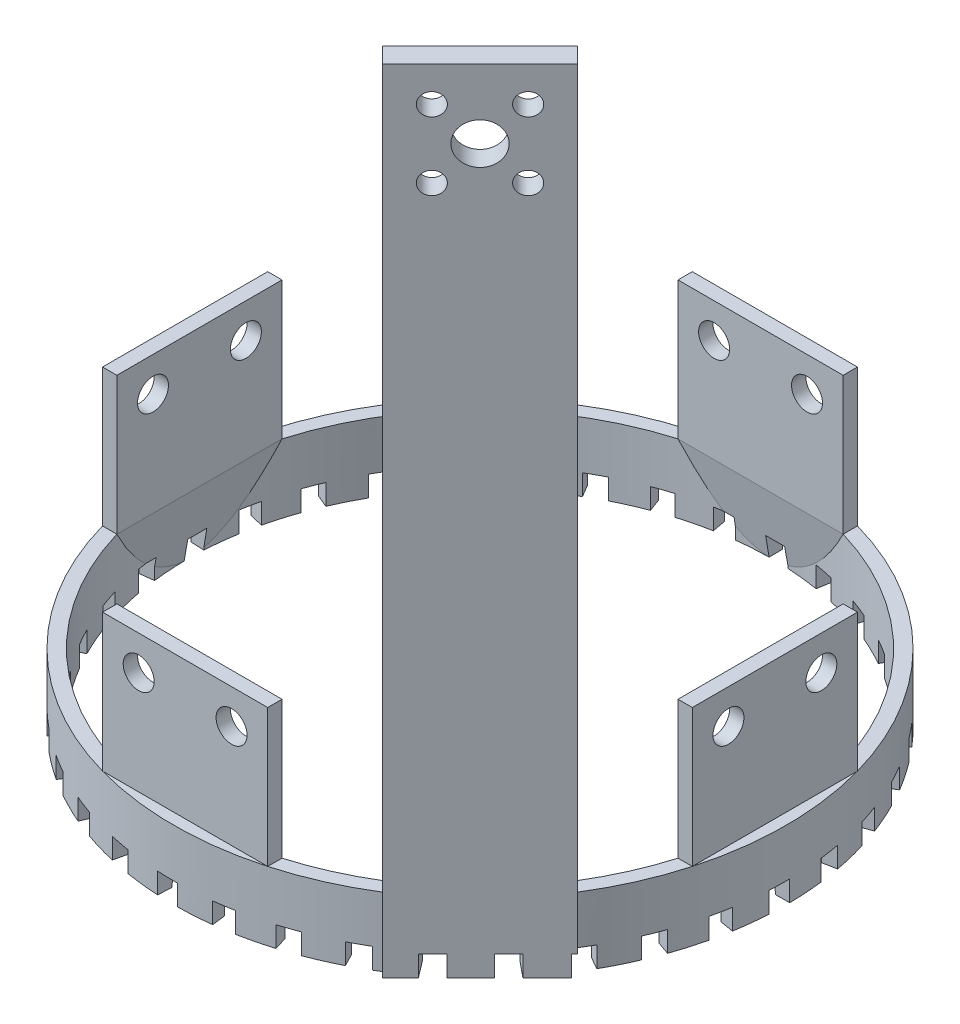
from build123d import *

# Parameters (mm, degrees)
SKETCH_1_R               = 44.5
SKETCH_1_R_2             = 42.5
EXTRUDE_1_DEPTH          = 10
SKETCH_6_W               = 24
SKETCH_6_H               = 2.080787458
SKETCH_6_W_2             = 2.080787458
SKETCH_6_H_2             = 24
EXTRUDE_3_DEPTH          = 20
SKETCH_7_R               = 2.25
CUT_EXTRUDE_1_DEPTH      = 90
SKETCH_8_R               = 2.25
CUT_EXTRUDE_2_DEPTH      = 90
EXTRUDE_4_DEPTH          = 24
EXTRUDE_5_DEPTH          = 24
EXTRUDE_6_DEPTH          = 105
EXTRUDE_6_DEPTH_BACK     = 10
EXTRUDE_11_DEPTH         = 20
SKETCH_14_R              = 1.6
SKETCH_14_R_2            = 3
CUT_EXTRUDE_4_DEPTH      = 20.570653934
CUT_EXTRUDE_4_DEPTH_BACK = 107.294353117
CUT_EXTRUDE_6_DEPTH      = 3


with BuildPart() as part:
    # 草图1 → 凸台-拉伸1 (new body)
    with BuildSketch(Plane(origin=(0, 0, 0), x_dir=(1, 0, 0), z_dir=(0, 1, 0))):
        Circle(SKETCH_1_R)
        Circle(SKETCH_1_R_2, mode=Mode.SUBTRACT)
    extrude(amount=EXTRUDE_1_DEPTH)

    # 草图6 → 凸台-拉伸3 (add)
    with BuildSketch(Plane(origin=(0, 10, 0), x_dir=(1, 0, 0), z_dir=(0, 1, 0))):
        with Locations((0, 41.811093993)):
            Rectangle(SKETCH_6_W, SKETCH_6_H)
        with Locations((41.811093993, 0)):
            Rectangle(SKETCH_6_W_2, SKETCH_6_H_2)
        with Locations((0, -41.811093993)):
            Rectangle(SKETCH_6_W, SKETCH_6_H)
        with Locations((-41.811093993, 0)):
            Rectangle(SKETCH_6_W_2, SKETCH_6_H_2)
    extrude(amount=EXTRUDE_3_DEPTH)

    # 草图7 → 切除-拉伸1 (cut, through all)
    with BuildSketch(Plane.ZY.offset(44.5)):
        with Locations((-6.75, 25)):
            Circle(SKETCH_7_R)
        with Locations((6.75, 25)):
            Circle(SKETCH_7_R)
    extrude(amount=-CUT_EXTRUDE_1_DEPTH, mode=Mode.SUBTRACT)

    # 草图8 → 切除-拉伸2 (cut, through all)
    with BuildSketch(Plane(origin=(0, 0, -44.5), x_dir=(-1, 0, 0), z_dir=(0, 0, -1))):
        with Locations((-6.75, 25)):
            Circle(SKETCH_8_R)
        with Locations((6.75, 25)):
            Circle(SKETCH_8_R)
    extrude(amount=-CUT_EXTRUDE_2_DEPTH, mode=Mode.SUBTRACT)

    # 草图9 → 凸台-拉伸4 (add)
    with BuildSketch(Plane(origin=(12, 0, 0), x_dir=(0, 0, -1), z_dir=(1, 0, 0))):
        Polygon((-42.851487722, 0), (-42.851487722, 10), (-40.770700264, 10), (-42.5, 0), align=None)
        Polygon((42.851487722, 10), (40.770700264, 10), (42.5, 0), (42.851487722, 0), align=None)
    extrude(amount=-EXTRUDE_4_DEPTH)

    # 草图10 → 凸台-拉伸5 (add)
    with BuildSketch(Plane.XY.offset(12)):
        Polygon((-42.851487722, 0), (-42.851487722, 10), (-40.770700264, 10), (-42.5, 0), align=None)
        Polygon((42.851487722, 10), (40.770700264, 10), (42.5, 0), (42.851487722, 0), align=None)
    extrude(amount=-EXTRUDE_5_DEPTH)

    # 草图12 → 凸台-拉伸6 (add, two sides)
    with BuildSketch(Plane(origin=(0, 10, 0), x_dir=(1, 0, 0), z_dir=(0, 1, 0))) as extrude_6_sk:
        Polygon((36.279371426, -22.137235802), (38.537319575, -24.395183951), (24.395183951, -38.537319575), (22.106388525, -36.248524149), align=None)
    extrude(amount=EXTRUDE_6_DEPTH)
    extrude(extrude_6_sk.sketch, amount=-EXTRUDE_6_DEPTH_BACK)

    # 草图13 → 凸台-拉伸11 (add)
    with BuildSketch(Plane(origin=(-7.071067812, 0, 7.071067812), x_dir=(0.707106781, 0, 0.707106781), z_dir=(-0.707106781, 0, 0.707106781))):
        Polygon((43.361849592, 10), (41.263154468, 10), (42.5, 0), (43.361849592, 0), align=None)
    extrude(amount=-EXTRUDE_11_DEPTH)

    # 草图14 → 切除-拉伸4 (cut, two sides)
    with BuildSketch(Plane(origin=(30.661457891, 0, 30.661457891), x_dir=(0.707106781, 0, -0.707106781), z_dir=(0.707106781, 0, 0.707106781))) as cut_extrude_4_sk:
        with Locations((4.949747468, 109.949747468)):
            Circle(SKETCH_14_R)
        with Locations((-4.949747468, 100.050252532)):
            Circle(SKETCH_14_R)
        with Locations((-4.949747468, 109.949747468)):
            Circle(SKETCH_14_R)
        with Locations((4.949747468, 100.050252532)):
            Circle(SKETCH_14_R)
        with Locations((0, 105)):
            Circle(SKETCH_14_R_2)
    extrude(amount=CUT_EXTRUDE_4_DEPTH, mode=Mode.SUBTRACT)
    extrude(cut_extrude_4_sk.sketch, amount=-CUT_EXTRUDE_4_DEPTH_BACK, mode=Mode.SUBTRACT)

    # 草图15 → 切除-拉伸6 (cut)
    with BuildSketch(Plane.XZ):
        with BuildLine():
            Line((-13.50434863, 38.469241844), (-15.107174155, 43.035140165))
            ThreePointArc((-15.107174155, 43.035140165), (-16.509241917, 42.516995794), (-17.893578126, 41.953186552))
            Line((-17.893578126, 41.953186552), (-16.014979854, 37.493605058))
            ThreePointArc((-16.014979854, 37.493605058), (-14.767723431, 38.002162368), (-13.50434863, 38.469241844))
        make_face()
        with BuildLine():
            Line((-9.260980133, 39.704965017), (-10.336640075, 44.423010613))
            ThreePointArc((-10.336640075, 44.423010613), (-8.875430597, 44.737866866), (-7.404688568, 45.004672949))
            Line((-7.404688568, 45.004672949), (-6.619073488, 40.229813151))
            ThreePointArc((-6.619073488, 40.229813151), (-7.944362286, 39.989212394), (-9.260980133, 39.704965017))
        make_face()
        with BuildLine():
            Line((-2.225590215, 40.709909705), (-2.465628447, 45.543063976))
            ThreePointArc((-2.465628447, 45.543063976), (-0.971943809, 45.599400492), (0.522784733, 45.606761518))
            Line((0.522784733, 45.606761518), (0.467318853, 40.768021942))
            ThreePointArc((0.467318853, 40.768021942), (-0.879615714, 40.761210436), (-2.225590215, 40.709909705))
        make_face()
        with BuildLine():
            Line((4.877423134, 40.477904387), (5.480300054, 45.279314387))
            ThreePointArc((5.480300054, 45.279314387), (6.961074999, 45.075419408), (8.434373485, 44.823111716))
            Line((8.434373485, 44.823111716), (7.539511947, 40.067515017))
            ThreePointArc((7.539511947, 40.067515017), (6.211857537, 40.294699725), (4.877423134, 40.477904387))
        make_face()
        with BuildLine():
            Line((11.83223845, 39.015998427), (13.259712412, 43.639775741))
            ThreePointArc((13.259712412, 43.639775741), (14.682585067, 43.181844516), (16.089688067, 42.677534347))
            Line((16.089688067, 42.677534347), (14.382620785, 38.149576922))
            ThreePointArc((14.382620785, 38.149576922), (13.11458664, 38.603854953), (11.83223845, 39.015998427))
        make_face()
        with BuildLine():
            Line((18.427537187, 36.368611098), (20.636235117, 40.674264593))
            ThreePointArc((20.636235117, 40.674264593), (21.957972216, 39.976211128), (23.256125619, 39.235221692))
            Line((23.256125619, 39.235221692), (20.788720969, 35.072483238))
            ThreePointArc((20.788720969, 35.072483238), (19.618835664, 35.740051583), (18.427537187, 36.368611098))
        make_face()
        with BuildLine():
            Line((24.462924533, 32.616181924), (27.385736261, 36.472886498))
            ThreePointArc((27.385736261, 36.472886498), (28.566177491, 35.555920794), (29.715937561, 34.60076668))
            Line((29.715937561, 34.60076668), (26.563166386, 30.929729897))
            ThreePointArc((26.563166386, 30.929729897), (25.526976294, 31.790304831), (24.462924533, 32.616181924))
        make_face()
        with BuildLine():
            Line((29.755018295, 27.872726567), (33.303135666, 31.163298202))
            ThreePointArc((33.303135666, 31.163298202), (34.306413919, 30.055281799), (35.272845778, 28.914984882))
            Line((35.272845778, 28.914984882), (31.530503434, 25.847192365))
            ThreePointArc((31.530503434, 25.847192365), (30.659492667, 26.874625754), (29.755018295, 27.872726567))
        make_face()
        with BuildLine():
            Line((34.143020883, 22.282372518), (38.208636146, 24.90682886))
            ThreePointArc((38.208636146, 24.90682886), (39.004267319, 23.641428276), (39.758006425, 22.350635899))
            Line((39.758006425, 22.350635899), (35.539802091, 19.979300973))
            ThreePointArc((35.539802091, 19.979300973), (34.86043587, 21.142374772), (34.143020883, 22.282372518))
        make_face()
        with BuildLine():
            Line((37.493605058, 16.014979854), (41.953186552, 17.893578126))
            ThreePointArc((41.953186552, 17.893578126), (42.516995794, 16.509241917), (43.035140165, 15.107174155))
            Line((43.035140165, 15.107174155), (38.469241844, 13.50434863))
            ThreePointArc((38.469241844, 13.50434863), (38.002162368, 14.767723431), (37.493605058, 16.014979854))
        make_face()
        with BuildLine():
            Line((39.704965017, 9.260980133), (44.423010613, 10.336640075))
            ThreePointArc((44.423010613, 10.336640075), (44.737866866, 8.875430597), (45.004672949, 7.404688568))
            Line((45.004672949, 7.404688568), (40.229813151, 6.619073488))
            ThreePointArc((40.229813151, 6.619073488), (39.989212394, 7.944362286), (39.704965017, 9.260980133))
        make_face()
        with BuildLine():
            Line((40.709909705, 2.225590215), (45.543063976, 2.465628447))
            ThreePointArc((45.543063976, 2.465628447), (45.599400492, 0.971943809), (45.606761518, -0.522784733))
            Line((45.606761518, -0.522784733), (40.768021942, -0.467318853))
            ThreePointArc((40.768021942, -0.467318853), (40.761210436, 0.879615714), (40.709909705, 2.225590215))
        make_face()
        with BuildLine():
            Line((40.477904387, -4.877423134), (45.279314387, -5.480300054))
            ThreePointArc((45.279314387, -5.480300054), (45.075419408, -6.961074999), (44.823111716, -8.434373485))
            Line((44.823111716, -8.434373485), (40.067515017, -7.539511947))
            ThreePointArc((40.067515017, -7.539511947), (40.294699725, -6.211857537), (40.477904387, -4.877423134))
        make_face()
        with BuildLine():
            Line((39.015998427, -11.83223845), (43.639775741, -13.259712412))
            ThreePointArc((43.639775741, -13.259712412), (43.181844516, -14.682585067), (42.677534347, -16.089688067))
            Line((42.677534347, -16.089688067), (38.149576922, -14.382620785))
            ThreePointArc((38.149576922, -14.382620785), (38.603854953, -13.11458664), (39.015998427, -11.83223845))
        make_face()
        with BuildLine():
            Line((36.368611098, -18.427537187), (40.674264593, -20.636235117))
            ThreePointArc((40.674264593, -20.636235117), (39.976211128, -21.957972216), (39.235221692, -23.256125619))
            Line((39.235221692, -23.256125619), (35.072483238, -20.788720969))
            ThreePointArc((35.072483238, -20.788720969), (35.740051583, -19.618835664), (36.368611098, -18.427537187))
        make_face()
        with BuildLine():
            Line((32.616181924, -24.462924533), (36.472886498, -27.385736261))
            ThreePointArc((36.472886498, -27.385736261), (35.555920794, -28.566177491), (34.60076668, -29.715937561))
            Line((34.60076668, -29.715937561), (30.929729897, -26.563166386))
            ThreePointArc((30.929729897, -26.563166386), (31.790304831, -25.526976294), (32.616181924, -24.462924533))
        make_face()
        with BuildLine():
            Line((27.872726567, -29.755018295), (31.163298202, -33.303135666))
            ThreePointArc((31.163298202, -33.303135666), (30.055281799, -34.306413919), (28.914984882, -35.272845778))
            Line((28.914984882, -35.272845778), (25.847192365, -31.530503434))
            ThreePointArc((25.847192365, -31.530503434), (26.874625754, -30.659492667), (27.872726567, -29.755018295))
        make_face()
        with BuildLine():
            Line((22.282372518, -34.143020883), (24.90682886, -38.208636146))
            ThreePointArc((24.90682886, -38.208636146), (23.641428276, -39.004267319), (22.350635899, -39.758006425))
            Line((22.350635899, -39.758006425), (19.979300973, -35.539802091))
            ThreePointArc((19.979300973, -35.539802091), (21.142374772, -34.86043587), (22.282372518, -34.143020883))
        make_face()
        with BuildLine():
            Line((16.014979854, -37.493605058), (17.893578126, -41.953186552))
            ThreePointArc((17.893578126, -41.953186552), (16.509241917, -42.516995794), (15.107174155, -43.035140165))
            Line((15.107174155, -43.035140165), (13.50434863, -38.469241844))
            ThreePointArc((13.50434863, -38.469241844), (14.767723431, -38.002162368), (16.014979854, -37.493605058))
        make_face()
        with BuildLine():
            Line((9.260980133, -39.704965017), (10.336640075, -44.423010613))
            ThreePointArc((10.336640075, -44.423010613), (8.875430597, -44.737866866), (7.404688568, -45.004672949))
            Line((7.404688568, -45.004672949), (6.619073488, -40.229813151))
            ThreePointArc((6.619073488, -40.229813151), (7.944362286, -39.989212394), (9.260980133, -39.704965017))
        make_face()
        with BuildLine():
            Line((2.225590215, -40.709909705), (2.465628447, -45.543063976))
            ThreePointArc((2.465628447, -45.543063976), (0.971943809, -45.599400492), (-0.522784733, -45.606761518))
            Line((-0.522784733, -45.606761518), (-0.467318853, -40.768021942))
            ThreePointArc((-0.467318853, -40.768021942), (0.879615714, -40.761210436), (2.225590215, -40.709909705))
        make_face()
        with BuildLine():
            Line((-4.877423134, -40.477904387), (-5.480300054, -45.279314387))
            ThreePointArc((-5.480300054, -45.279314387), (-6.961074999, -45.075419408), (-8.434373485, -44.823111716))
            Line((-8.434373485, -44.823111716), (-7.539511947, -40.067515017))
            ThreePointArc((-7.539511947, -40.067515017), (-6.211857537, -40.294699725), (-4.877423134, -40.477904387))
        make_face()
        with BuildLine():
            Line((-11.83223845, -39.015998427), (-13.259712412, -43.639775741))
            ThreePointArc((-13.259712412, -43.639775741), (-14.682585067, -43.181844516), (-16.089688067, -42.677534347))
            Line((-16.089688067, -42.677534347), (-14.382620785, -38.149576922))
            ThreePointArc((-14.382620785, -38.149576922), (-13.11458664, -38.603854953), (-11.83223845, -39.015998427))
        make_face()
        with BuildLine():
            Line((-18.427537187, -36.368611098), (-20.636235117, -40.674264593))
            ThreePointArc((-20.636235117, -40.674264593), (-21.957972216, -39.976211128), (-23.256125619, -39.235221692))
            Line((-23.256125619, -39.235221692), (-20.788720969, -35.072483238))
            ThreePointArc((-20.788720969, -35.072483238), (-19.618835664, -35.740051583), (-18.427537187, -36.368611098))
        make_face()
        with BuildLine():
            Line((-24.462924533, -32.616181924), (-27.385736261, -36.472886498))
            ThreePointArc((-27.385736261, -36.472886498), (-28.566177491, -35.555920794), (-29.715937561, -34.60076668))
            Line((-29.715937561, -34.60076668), (-26.563166386, -30.929729897))
            ThreePointArc((-26.563166386, -30.929729897), (-25.526976294, -31.790304831), (-24.462924533, -32.616181924))
        make_face()
        with BuildLine():
            Line((-29.755018295, -27.872726567), (-33.303135666, -31.163298202))
            ThreePointArc((-33.303135666, -31.163298202), (-34.306413919, -30.055281799), (-35.272845778, -28.914984882))
            Line((-35.272845778, -28.914984882), (-31.530503434, -25.847192365))
            ThreePointArc((-31.530503434, -25.847192365), (-30.659492667, -26.874625754), (-29.755018295, -27.872726567))
        make_face()
        with BuildLine():
            Line((-34.143020883, -22.282372518), (-38.208636146, -24.90682886))
            ThreePointArc((-38.208636146, -24.90682886), (-39.004267319, -23.641428276), (-39.758006425, -22.350635899))
            Line((-39.758006425, -22.350635899), (-35.539802091, -19.979300973))
            ThreePointArc((-35.539802091, -19.979300973), (-34.86043587, -21.142374772), (-34.143020883, -22.282372518))
        make_face()
        with BuildLine():
            Line((-37.493605058, -16.014979854), (-41.953186552, -17.893578126))
            ThreePointArc((-41.953186552, -17.893578126), (-42.516995794, -16.509241917), (-43.035140165, -15.107174155))
            Line((-43.035140165, -15.107174155), (-38.469241844, -13.50434863))
            ThreePointArc((-38.469241844, -13.50434863), (-38.002162368, -14.767723431), (-37.493605058, -16.014979854))
        make_face()
        with BuildLine():
            Line((-39.704965017, -9.260980133), (-44.423010613, -10.336640075))
            ThreePointArc((-44.423010613, -10.336640075), (-44.737866866, -8.875430597), (-45.004672949, -7.404688568))
            Line((-45.004672949, -7.404688568), (-40.229813151, -6.619073488))
            ThreePointArc((-40.229813151, -6.619073488), (-39.989212394, -7.944362286), (-39.704965017, -9.260980133))
        make_face()
        with BuildLine():
            Line((-40.709909705, -2.225590215), (-45.543063976, -2.465628447))
            ThreePointArc((-45.543063976, -2.465628447), (-45.599400492, -0.971943809), (-45.606761518, 0.522784733))
            Line((-45.606761518, 0.522784733), (-40.768021942, 0.467318853))
            ThreePointArc((-40.768021942, 0.467318853), (-40.761210436, -0.879615714), (-40.709909705, -2.225590215))
        make_face()
        with BuildLine():
            Line((-40.477904387, 4.877423134), (-45.279314387, 5.480300054))
            ThreePointArc((-45.279314387, 5.480300054), (-45.075419408, 6.961074999), (-44.823111716, 8.434373485))
            Line((-44.823111716, 8.434373485), (-40.067515017, 7.539511947))
            ThreePointArc((-40.067515017, 7.539511947), (-40.294699725, 6.211857537), (-40.477904387, 4.877423134))
        make_face()
        with BuildLine():
            Line((-39.015998427, 11.83223845), (-43.639775741, 13.259712412))
            ThreePointArc((-43.639775741, 13.259712412), (-43.181844516, 14.682585067), (-42.677534347, 16.089688067))
            Line((-42.677534347, 16.089688067), (-38.149576922, 14.382620785))
            ThreePointArc((-38.149576922, 14.382620785), (-38.603854953, 13.11458664), (-39.015998427, 11.83223845))
        make_face()
        with BuildLine():
            Line((-36.368611098, 18.427537187), (-40.674264593, 20.636235117))
            ThreePointArc((-40.674264593, 20.636235117), (-39.976211128, 21.957972216), (-39.235221692, 23.256125619))
            Line((-39.235221692, 23.256125619), (-35.072483238, 20.788720969))
            ThreePointArc((-35.072483238, 20.788720969), (-35.740051583, 19.618835664), (-36.368611098, 18.427537187))
        make_face()
        with BuildLine():
            Line((-32.616181924, 24.462924533), (-36.472886498, 27.385736261))
            ThreePointArc((-36.472886498, 27.385736261), (-35.555920794, 28.566177491), (-34.60076668, 29.715937561))
            Line((-34.60076668, 29.715937561), (-30.929729897, 26.563166386))
            ThreePointArc((-30.929729897, 26.563166386), (-31.790304831, 25.526976294), (-32.616181924, 24.462924533))
        make_face()
        with BuildLine():
            Line((-27.872726567, 29.755018295), (-31.163298202, 33.303135666))
            ThreePointArc((-31.163298202, 33.303135666), (-30.055281799, 34.306413919), (-28.914984882, 35.272845778))
            Line((-28.914984882, 35.272845778), (-25.847192365, 31.530503434))
            ThreePointArc((-25.847192365, 31.530503434), (-26.874625754, 30.659492667), (-27.872726567, 29.755018295))
        make_face()
        with BuildLine():
            Line((-22.282372518, 34.143020883), (-24.90682886, 38.208636146))
            ThreePointArc((-24.90682886, 38.208636146), (-23.641428276, 39.004267319), (-22.350635899, 39.758006425))
            Line((-22.350635899, 39.758006425), (-19.979300973, 35.539802091))
            ThreePointArc((-19.979300973, 35.539802091), (-21.142374772, 34.86043587), (-22.282372518, 34.143020883))
        make_face()
    extrude(amount=-CUT_EXTRUDE_6_DEPTH, mode=Mode.SUBTRACT)


solid = part.part
